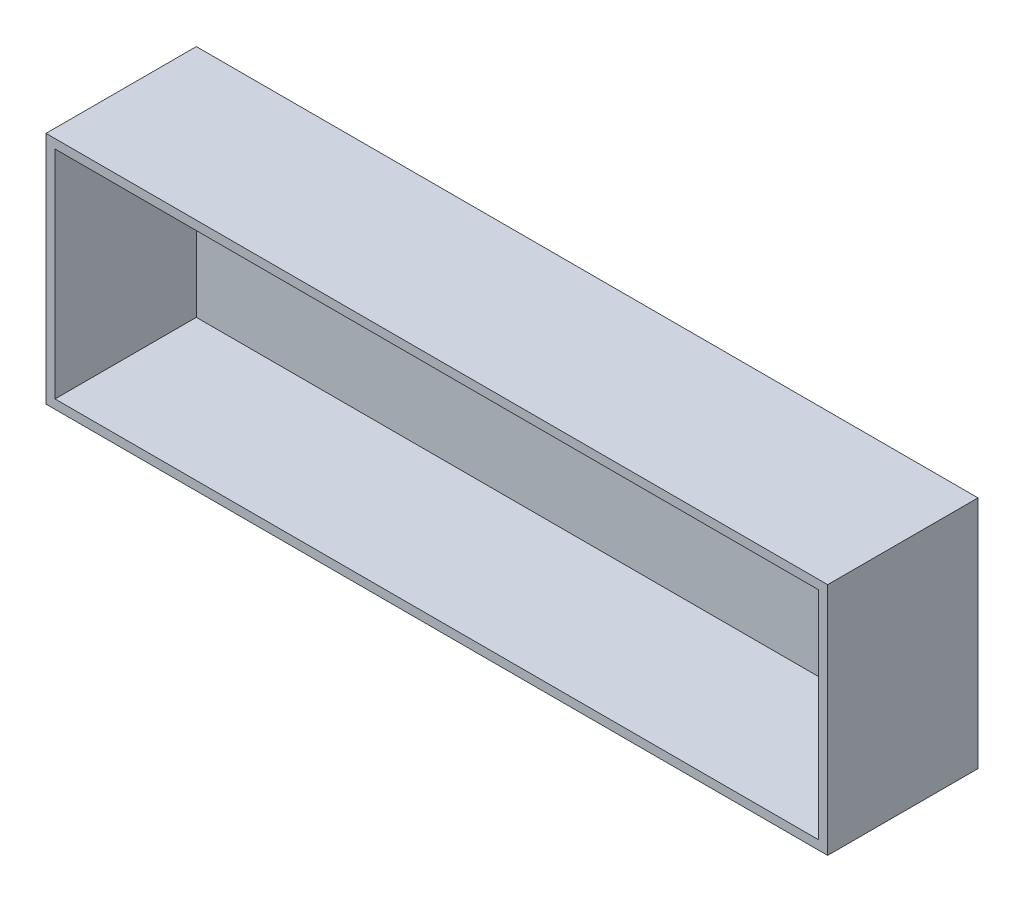
from build123d import *

# Parameters (mm, degrees)
SKETCH_1_W      = 260
SKETCH_1_H      = 78
EXTRUDE_1_DEPTH = 50
SHELL_1_T       = -3


with BuildPart() as part:
    # 草图1 → 凸台-拉伸1 (new body)
    with BuildSketch(Plane.XY):
        Rectangle(SKETCH_1_W, SKETCH_1_H)
    extrude(amount=EXTRUDE_1_DEPTH)

    # 抽壳1
    shell_1_openings = [part.faces().sort_by_distance(p)[0] for p in [
        (0, 0, 50),
    ]]
    offset(amount=SHELL_1_T, openings=shell_1_openings, kind=Kind.INTERSECTION)


solid = part.part
